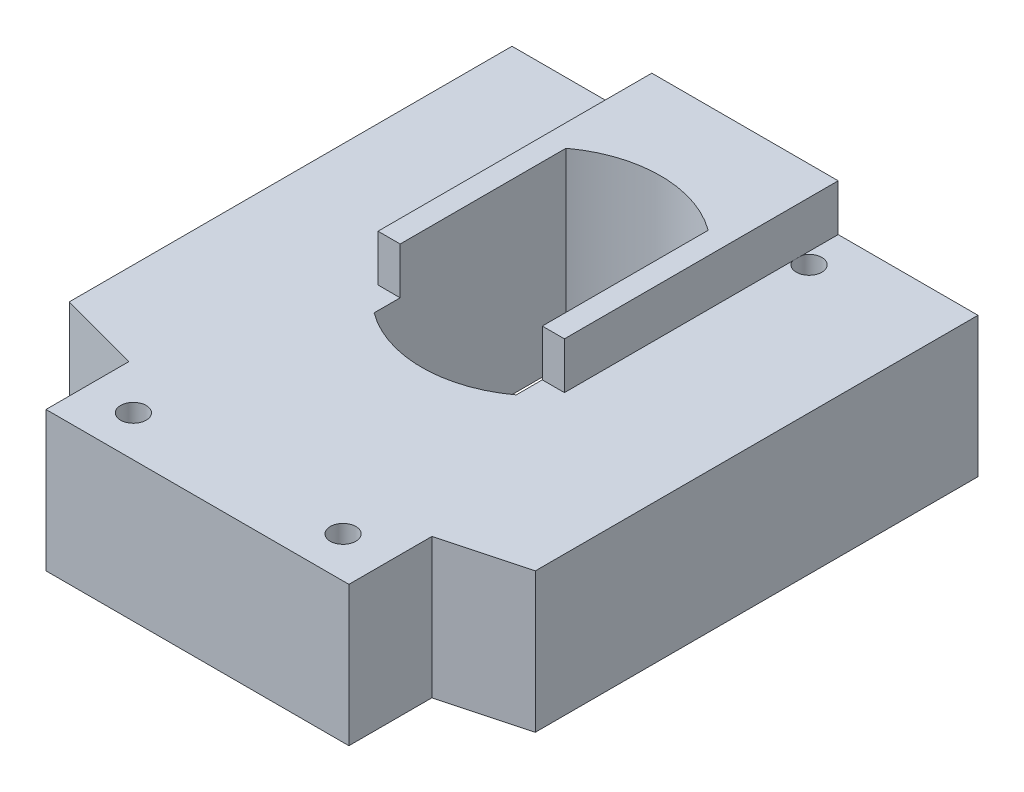
from build123d import *

# Parameters (mm, degrees)
SKETCH1_W               = 26
SKETCH1_H               = 47
SKETCH1_R               = 1.1
BOSS_EXTRUDE1_DEPTH     = 12
SKETCH2_3_W             = 16
SKETCH2_3_H             = 4
BOSS_EXTRUDE2_DEPTH     = 23.5
CUT_EXTRUDE3_DEPTH      = 5
CUT_EXTRUDE3_DEPTH_BACK = 13


with BuildPart() as part:
    # Sketch1 → Boss-Extrude1 (new body)
    with BuildSketch(Plane(origin=(0, 0, 0), x_dir=(1, 0, 0), z_dir=(0, 1, 0))):
        Polygon((-13, -16.375644347), (-13, 23.5), (-20, 23.5), (-20, -14.5), align=None)
        Rectangle(SKETCH1_W, SKETCH1_H)
        with Locations((9, -20)):
            Circle(SKETCH1_R, mode=Mode.SUBTRACT)
        with Locations((-9, -20)):
            Circle(SKETCH1_R, mode=Mode.SUBTRACT)
        with Locations((9, 20)):
            Circle(SKETCH1_R, mode=Mode.SUBTRACT)
        with Locations((-9, 20)):
            Circle(SKETCH1_R, mode=Mode.SUBTRACT)
        Polygon((20, 23.5), (13, 23.5), (13, -16.375644347), (20, -14.5), align=None)
    extrude(amount=-BOSS_EXTRUDE1_DEPTH)

    # Sketch2_3 → Boss-Extrude2 (add)
    with BuildSketch(Plane.XY):
        with Locations((0, 2)):
            Rectangle(SKETCH2_3_W, SKETCH2_3_H)
    extrude(amount=-BOSS_EXTRUDE2_DEPTH)

    # Sketch3 → Cut-Extrude3 (cut, two sides)
    with BuildSketch(Plane(origin=(0, 0, 0), x_dir=(1, 0, 0), z_dir=(0, 1, 0))) as cut_extrude3_sk:
        with BuildLine():
            ThreePointArc((6.1, 14.237262895), (0, 16.25), (-6.1, 14.237262895))
            Line((-6.1, 14.237262895), (-6.1, -2.237262895))
            ThreePointArc((-6.1, -2.237262895), (0, -4.25), (6.1, -2.237262895))
            Line((6.1, -2.237262895), (6.1, 14.237262895))
        make_face()
    extrude(amount=CUT_EXTRUDE3_DEPTH, mode=Mode.SUBTRACT)
    extrude(cut_extrude3_sk.sketch, amount=-CUT_EXTRUDE3_DEPTH_BACK, mode=Mode.SUBTRACT)


solid = part.part
